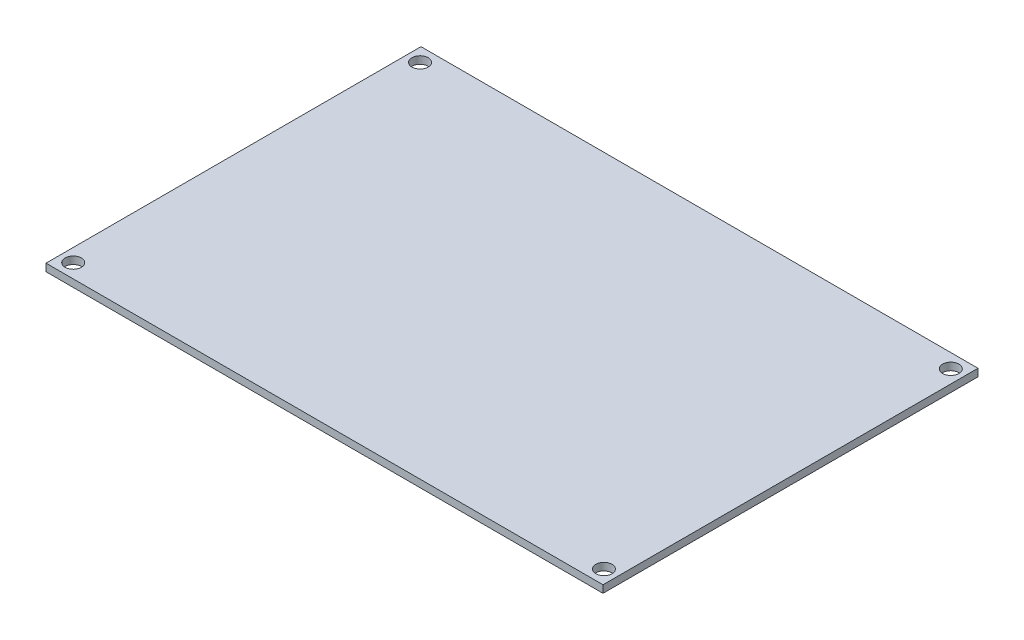
from build123d import *

# Parameters (mm, degrees)
SKETCH1_W           = 119.65
SKETCH1_H           = 80.55
SKETCH1_R           = 1.75
BOSS_EXTRUDE1_DEPTH = 1.6


with BuildPart() as part:
    # Sketch1 → Boss-Extrude1 (new body)
    with BuildSketch(Plane(origin=(0, 0, 0), x_dir=(1, 0, 0), z_dir=(0, 1, 0))):
        Rectangle(SKETCH1_W, SKETCH1_H)
        with Locations((-57, 37.25)):
            Circle(SKETCH1_R, mode=Mode.SUBTRACT)
        with Locations((57, 37.25)):
            Circle(SKETCH1_R, mode=Mode.SUBTRACT)
        with Locations((57, -37.25)):
            Circle(SKETCH1_R, mode=Mode.SUBTRACT)
        with Locations((-57, -37.25)):
            Circle(SKETCH1_R, mode=Mode.SUBTRACT)
    extrude(amount=BOSS_EXTRUDE1_DEPTH)


solid = part.part
